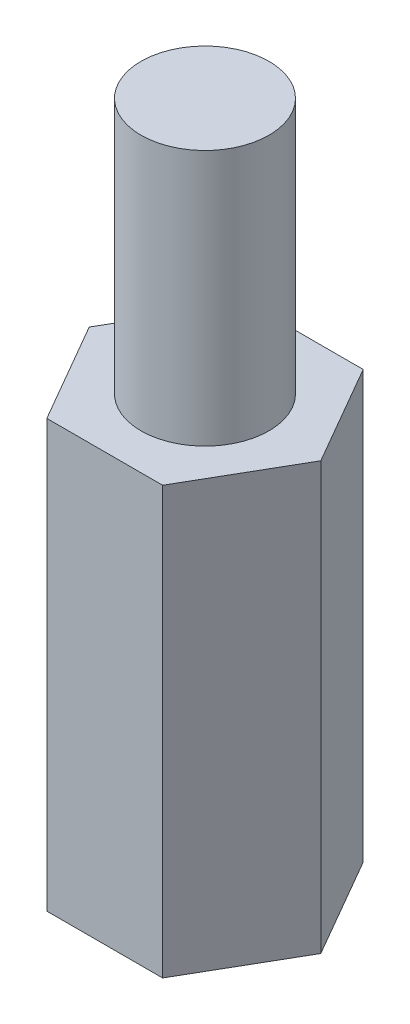
from build123d import *

# Parameters (mm, degrees)
EXTRUDE_1_DEPTH     = 10
SKETCH_2_R          = 1.5
EXTRUDE_2_DEPTH     = 6
SKETCH_3_R          = 1.5
CUT_EXTRUDE_1_DEPTH = 7


with BuildPart() as part:
    # 草图1 → 凸台-拉伸1 (new body)
    with BuildSketch(Plane(origin=(0, 0, 0), x_dir=(1, 0, 0), z_dir=(0, 1, 0))):
        Polygon((1.356773133, 2.35), (-1.356773133, 2.35), (-2.713546265, 0), (-1.356773133, -2.35), (1.356773133, -2.35), (2.713546265, 0), align=None)
    extrude(amount=EXTRUDE_1_DEPTH)

    # 草图2 → 凸台-拉伸2 (add)
    with BuildSketch(Plane(origin=(0, 10, 0), x_dir=(1, 0, 0), z_dir=(0, 1, 0))):
        Circle(SKETCH_2_R)
    extrude(amount=EXTRUDE_2_DEPTH)

    # 草图3 → 切除-拉伸1 (cut)
    with BuildSketch(Plane.XZ):
        Circle(SKETCH_3_R)
    extrude(amount=-CUT_EXTRUDE_1_DEPTH, mode=Mode.SUBTRACT)


solid = part.part
